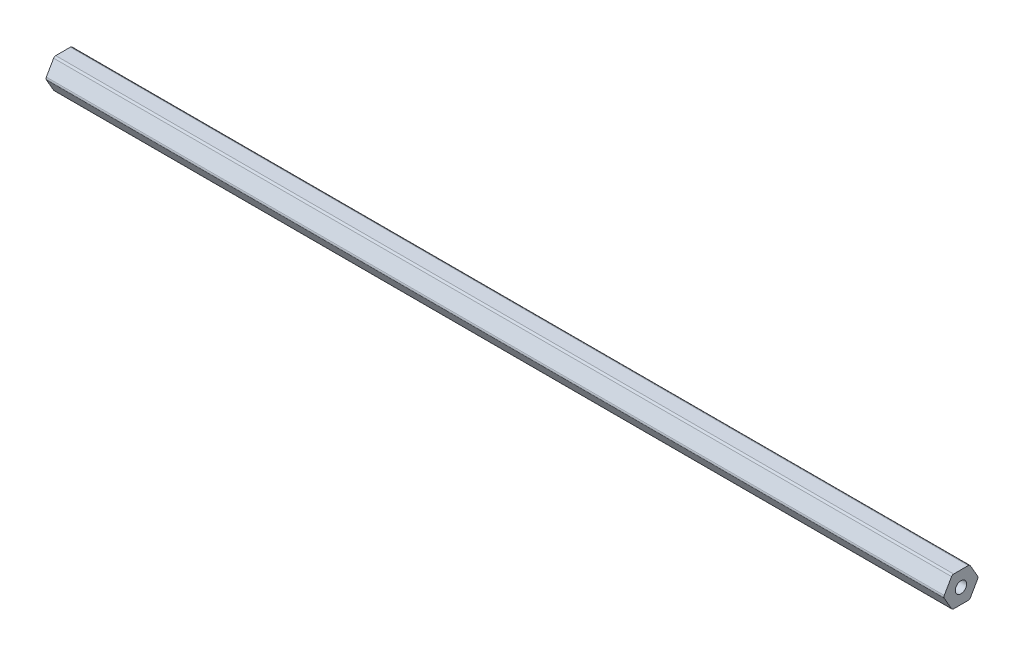
from build123d import *

# Parameters (mm, degrees)
SKETCH1_R           = 2.38125
BOSS_EXTRUDE1_DEPTH = 377.825


with BuildPart() as part:
    # Sketch1 → Boss-Extrude1 (new body)
    with BuildSketch(Plane(origin=(0, 0, 0), x_dir=(0, 0, -1), z_dir=(1, 0, 0))):
        with BuildLine():
            Line((7.039054482, 0.508), (3.959468146, 5.842))
            ThreePointArc((3.959468146, 5.842), (3.587586336, 6.21388181), (3.079586336, 6.35))
            Line((3.079586336, 6.35), (-3.079586336, 6.35))
            ThreePointArc((-3.079586336, 6.35), (-3.587586336, 6.21388181), (-3.959468146, 5.842))
            Line((-3.959468146, 5.842), (-7.039054482, 0.508))
            ThreePointArc((-7.039054482, 0.508), (-7.175172672, 0), (-7.039054482, -0.508))
            Line((-7.039054482, -0.508), (-3.959468146, -5.842))
            ThreePointArc((-3.959468146, -5.842), (-3.587586336, -6.21388181), (-3.079586336, -6.35))
            Line((-3.079586336, -6.35), (3.079586336, -6.35))
            ThreePointArc((3.079586336, -6.35), (3.587586336, -6.21388181), (3.959468146, -5.842))
            Line((3.959468146, -5.842), (7.039054482, -0.508))
            ThreePointArc((7.039054482, -0.508), (7.175172672, 0), (7.039054482, 0.508))
        make_face()
        Circle(SKETCH1_R, mode=Mode.SUBTRACT)
    extrude(amount=BOSS_EXTRUDE1_DEPTH)


solid = part.part
